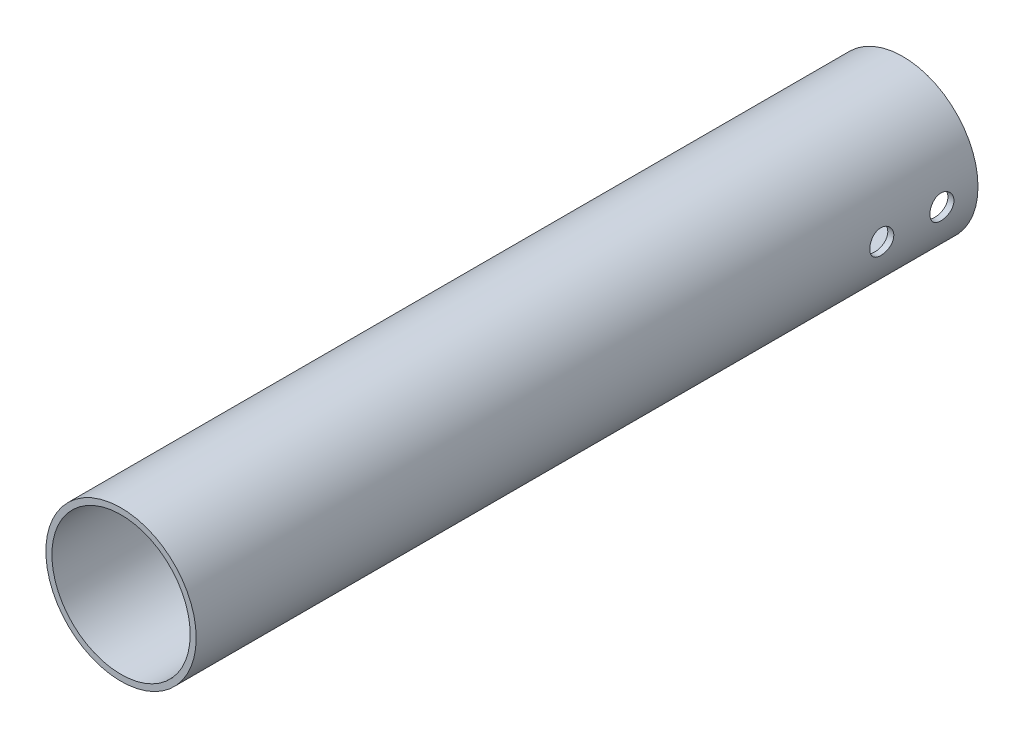
from build123d import *

# Parameters (mm, degrees)
SKETCH1_R               = 12.5
SKETCH1_R_2             = 11.5
BOSS_EXTRUDE1_DEPTH     = 130
SKETCH2_R               = 2
CUT_EXTRUDE1_DEPTH      = 13.5
CUT_EXTRUDE1_DEPTH_BACK = 13.5


with BuildPart() as part:
    # Sketch1 → Boss-Extrude1 (new body)
    with BuildSketch(Plane.XY):
        Circle(SKETCH1_R)
        Circle(SKETCH1_R_2, mode=Mode.SUBTRACT)
    extrude(amount=BOSS_EXTRUDE1_DEPTH)

    # Sketch2 → Cut-Extrude1 (cut, two sides)
    with BuildSketch(Plane(origin=(0, 0, 0), x_dir=(0, 0, -1), z_dir=(1, 0, 0))) as cut_extrude1_sk:
        with Locations((-6, 0)):
            Circle(SKETCH2_R)
        with Locations((-16, 0)):
            Circle(SKETCH2_R)
    extrude(amount=CUT_EXTRUDE1_DEPTH, mode=Mode.SUBTRACT)
    extrude(cut_extrude1_sk.sketch, amount=-CUT_EXTRUDE1_DEPTH_BACK, mode=Mode.SUBTRACT)


solid = part.part
